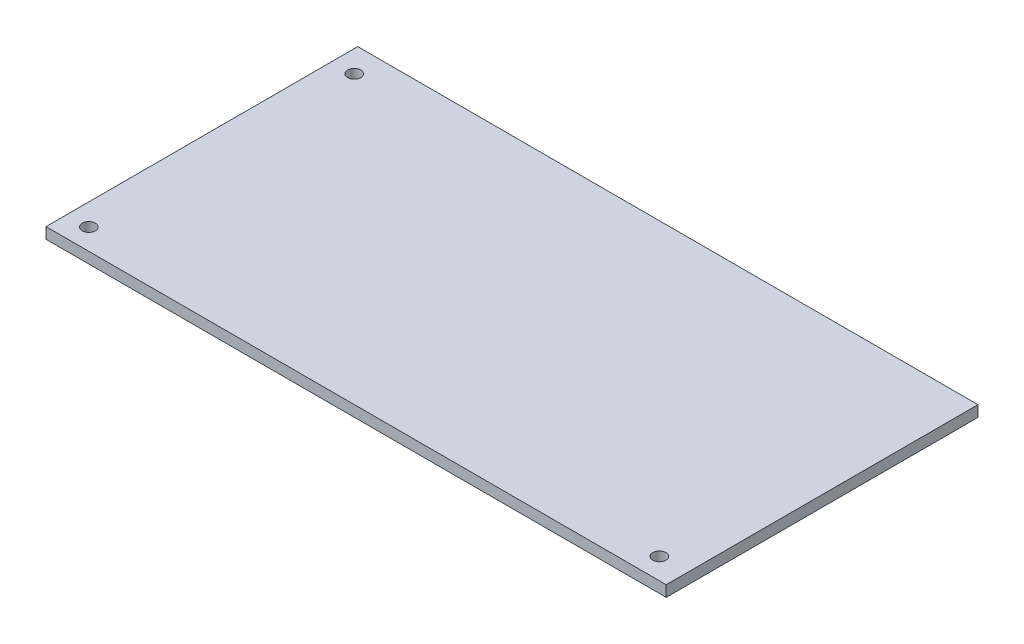
from build123d import *

# Parameters (mm, degrees)
ESBO_O1_W                = 93.5
ESBO_O1_H                = 47
RESSALTO_EXTRUS_O1_DEPTH = 1.66
ESBO_O2_R                = 1
CORTE_EXTRUS_O1_DEPTH    = 1.66


with BuildPart() as part:
    # Esboço1 → Ressalto-extrusão1 (new body)
    with BuildSketch(Plane(origin=(0, 0, 0), x_dir=(1, 0, 0), z_dir=(0, 1, 0))):
        with Locations((46.75, 23.5)):
            Rectangle(ESBO_O1_W, ESBO_O1_H)
    extrude(amount=RESSALTO_EXTRUS_O1_DEPTH)

    # Esboço2 → Corte-extrusão1 (cut)
    with BuildSketch(Plane(origin=(0, 1.66, 0), x_dir=(1, 0, 0), z_dir=(0, 1, 0))):
        with Locations((3.283811519, 43.179745345)):
            Circle(ESBO_O2_R)
        with Locations((89.283811519, 3.179745345)):
            Circle(ESBO_O2_R)
        with Locations((3.283811519, 3.179745345)):
            Circle(ESBO_O2_R)
    extrude(amount=-CORTE_EXTRUS_O1_DEPTH, mode=Mode.SUBTRACT)


solid = part.part
